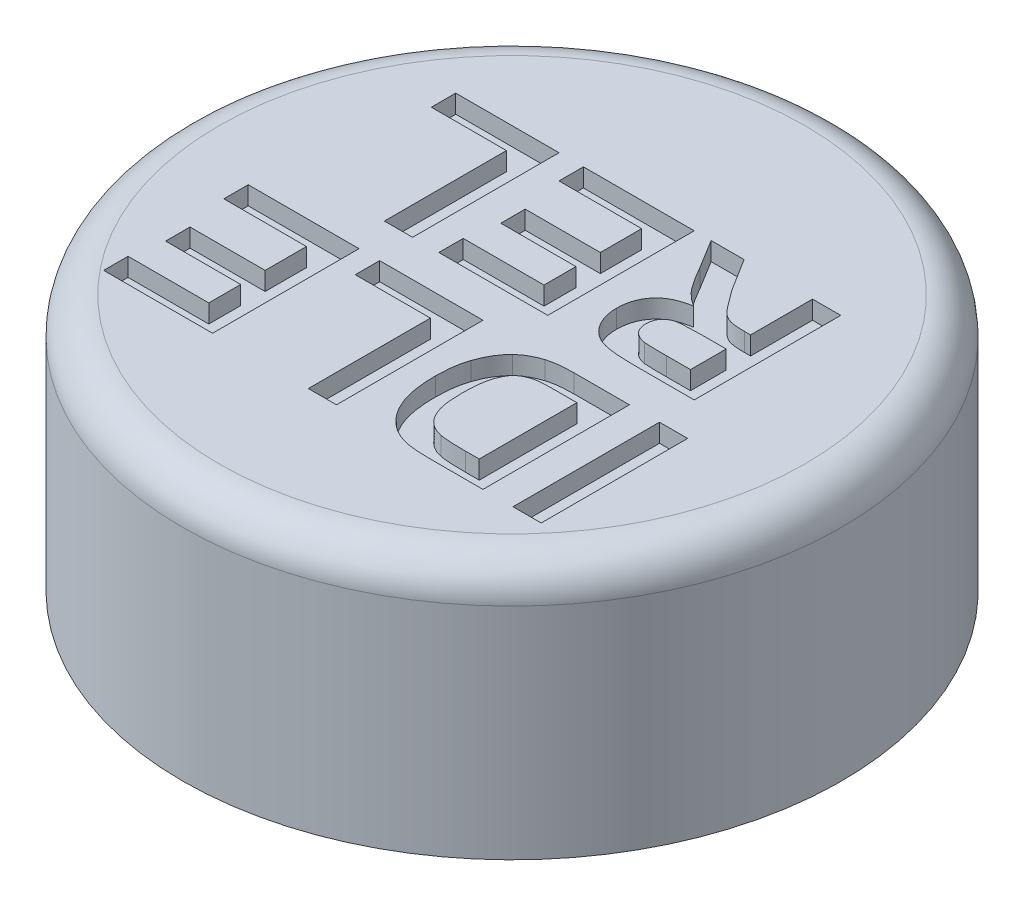
from build123d import *

# Parameters (mm, degrees)
SKETCH1_R           = 9
BOSS_EXTRUDE1_DEPTH = 7
SKETCH2_R           = 5.2
CUT_EXTRUDE1_DEPTH  = 4.5
SKETCH3_R           = 7.8
CUT_EXTRUDE2_DEPTH  = 3
SKETCH5_W           = 0.769230769
SKETCH5_H           = 4
CUT_EXTRUDE3_DEPTH  = 0.5
CUT_EXTRUDE4_DEPTH  = 0.5
FILLET1_R           = 1


with BuildPart() as part:
    # Sketch1 → Boss-Extrude1 (new body)
    with BuildSketch(Plane(origin=(0, 0, 0), x_dir=(1, 0, 0), z_dir=(0, 1, 0))):
        Circle(SKETCH1_R)
    extrude(amount=BOSS_EXTRUDE1_DEPTH)

    # Sketch2 → Cut-Extrude1 (cut)
    with BuildSketch(Plane.XZ):
        Circle(SKETCH2_R)
    extrude(amount=-CUT_EXTRUDE1_DEPTH, mode=Mode.SUBTRACT)

    # Sketch3 → Cut-Extrude2 (cut)
    with BuildSketch(Plane.XZ):
        Circle(SKETCH3_R)
    extrude(amount=-CUT_EXTRUDE2_DEPTH, mode=Mode.SUBTRACT)

    # Sketch5 → Cut-Extrude3 (cut)
    with BuildSketch(Plane(origin=(0, 7, 0), x_dir=(1, 0, 0), z_dir=(0, 1, 0))):
        with Locations((5.410256411, -3)):
            Rectangle(SKETCH5_W, SKETCH5_H)
        with BuildLine():
            Line((4.205128205, -5), (2.737980769, -5))
            add(Edge.make_bspline(
                [(2.737980769, -5), (2.697910591, -5.000020773), (2.619884646, -5.000061222), (2.506648571, -4.99536357), (2.400758284, -4.990638349), (2.302517715, -4.981179492), (2.211586037, -4.971264931), (2.127800077, -4.958712352), (2.051689115, -4.942624847), (2.003693585, -4.929937926), (1.980769231, -4.923878205)],
                knots=[0, 0, 0, 0, 0.000120195, 0.000234048, 0.000339965, 0.000438118, 0.000530057, 0.00061437, 0.000692161, 0.00076329, 0.00076329, 0.00076329, 0.00076329], degree=3))
            add(Edge.make_bspline(
                [(1.980769231, -4.923878205), (1.95205135, -4.914648987), (1.895037801, -4.896326238), (1.812261405, -4.862109411), (1.732255551, -4.824099599), (1.655496543, -4.78030702), (1.581999635, -4.731772666), (1.512013664, -4.677439933), (1.444620336, -4.619108388), (1.358904708, -4.534402974), (1.261026847, -4.416891893), (1.158022034, -4.261629883), (1.070596936, -4.091031256), (1.010066255, -3.938431484), (0.969887253, -3.808154415), (0.943491291, -3.703575528), (0.921020489, -3.593450986), (0.90389919, -3.477538623), (0.889277146, -3.356538592), (0.878759779, -3.229862465), (0.873557702, -3.097533027), (0.872390419, -3.007482273), (0.871794872, -2.961538462)],
                knots=[0, 0, 0, 0, 9.046e-05, 0.00017959, 0.00026847, 0.00035603, 0.000444481, 0.000532468, 0.000621641, 0.000711731, 0.000893734, 0.001079301, 0.001269598, 0.001467794, 0.001570948, 0.001678418, 0.001791248, 0.001907972, 0.002029822, 0.002156852, 0.002289183, 0.002427024, 0.002427024, 0.002427024, 0.002427024], degree=3))
            add(Edge.make_bspline(
                [(0.871794872, -2.961538462), (0.87337892, -2.882155908), (0.876447035, -2.728401286), (0.898619166, -2.506502016), (0.936077268, -2.301135264), (0.974814458, -2.172785814), (0.993589744, -2.110576923)],
                knots=[0, 0, 0, 0, 0.000238116, 0.000461202, 0.00066833, 0.000863145, 0.000863145, 0.000863145, 0.000863145], degree=3))
            add(Edge.make_bspline(
                [(0.993589744, -2.110576923), (1.006317082, -2.074915492), (1.031436326, -2.004532497), (1.074785292, -1.902887961), (1.121973712, -1.806504393), (1.173500658, -1.715626773), (1.228822086, -1.62970308), (1.288033978, -1.548754179), (1.351182657, -1.472951591), (1.397091862, -1.426764147), (1.419871795, -1.403846154)],
                knots=[0, 0, 0, 0, 0.000113573, 0.000224153, 0.0003313, 0.000435359, 0.000537377, 0.000637704, 0.000736092, 0.000832994, 0.000832994, 0.000832994, 0.000832994], degree=3))
            add(Edge.make_bspline(
                [(1.419871795, -1.403846154), (1.456929662, -1.370405848), (1.532776155, -1.301963434), (1.667214693, -1.217769185), (1.817768587, -1.142451393), (1.927370303, -1.104523727), (1.983974359, -1.084935897)],
                knots=[0, 0, 0, 0, 0.000149488, 0.000305958, 0.000474023, 0.000653524, 0.000653524, 0.000653524, 0.000653524], degree=3))
            add(Edge.make_bspline(
                [(1.983974359, -1.084935897), (2.006855011, -1.077914736), (2.05434262, -1.06334268), (2.129623695, -1.04766662), (2.210089518, -1.031664601), (2.296270547, -1.020078587), (2.387974587, -1.011424752), (2.485238968, -1.005058257), (2.588108042, -1.001051054), (2.658650161, -1.000355546), (2.694711538, -1)],
                knots=[0, 0, 0, 0, 7.1763e-05, 0.00014894, 0.000230502, 0.000317871, 0.000409641, 0.000506808, 0.000610251, 0.000718436, 0.000718436, 0.000718436, 0.000718436], degree=3))
            Line((2.694711538, -1), (4.205128205, -1))
            Line((4.205128205, -1), (4.205128205, -5))
        make_face()
        with BuildLine():
            Line((3.435897436, -4.333333333), (3.435897436, -1.666666667))
            Line((3.435897436, -1.666666667), (2.802884615, -1.666666667))
            add(Edge.make_bspline(
                [(2.802884615, -1.666666667), (2.774305746, -1.666893317), (2.719280505, -1.667329704), (2.639657572, -1.668611977), (2.566484766, -1.672083332), (2.499378764, -1.67567909), (2.438514268, -1.681619911), (2.383626448, -1.687462935), (2.335020835, -1.695637203), (2.305000814, -1.702089862), (2.290865385, -1.705128205)],
                knots=[0, 0, 0, 0, 8.5741e-05, 0.000165084, 0.000238872, 0.000305499, 0.000366654, 0.000422313, 0.000471053, 0.000514426, 0.000514426, 0.000514426, 0.000514426], degree=3))
            add(Edge.make_bspline(
                [(2.290865385, -1.705128205), (2.257758607, -1.713962736), (2.193275336, -1.731170071), (2.102734305, -1.769530175), (2.020806336, -1.815807442), (1.946119388, -1.871453867), (1.878810988, -1.941778078), (1.82135504, -2.03171723), (1.768181074, -2.138982356), (1.731767531, -2.241661907), (1.705629958, -2.333372881), (1.687936966, -2.410348165), (1.673954673, -2.493627638), (1.661928077, -2.582882626), (1.652210302, -2.677998353), (1.646163442, -2.779318297), (1.642036423, -2.886718431), (1.641368951, -2.960465891), (1.641025641, -2.998397436)],
                knots=[0, 0, 0, 0, 0.000102692, 0.000200018, 0.000294038, 0.000384423, 0.000478504, 0.000584289, 0.00070326, 0.000837095, 0.000910398, 0.000989316, 0.001073888, 0.001163639, 0.001259475, 0.00136064, 0.001468086, 0.001581879, 0.001581879, 0.001581879, 0.001581879], degree=3))
            add(Edge.make_bspline(
                [(1.641025641, -2.998397436), (1.641366309, -3.036329099), (1.642026246, -3.109809877), (1.646146967, -3.216409167), (1.65215975, -3.316133669), (1.66194711, -3.409106285), (1.673786, -3.495456774), (1.687936315, -3.575253977), (1.705508526, -3.647988287), (1.731729122, -3.734352219), (1.771023479, -3.831826218), (1.826640195, -3.937252659), (1.89115508, -4.029204972), (1.96492421, -4.107478292), (2.048966987, -4.172456802), (2.142944706, -4.225512064), (2.247177856, -4.267813901), (2.321557505, -4.285687757), (2.359775641, -4.294871795)],
                knots=[0, 0, 0, 0, 0.000113793, 0.000220439, 0.000320005, 0.000413449, 0.000500819, 0.000581446, 0.000656463, 0.000725154, 0.000852076, 0.00097109, 0.001082029, 0.00118802, 0.001292522, 0.001399462, 0.001510909, 0.001628695, 0.001628695, 0.001628695, 0.001628695], degree=3))
            add(Edge.make_bspline(
                [(2.359775641, -4.294871795), (2.376312881, -4.29794487), (2.412721552, -4.304710606), (2.47313859, -4.312607947), (2.544285023, -4.318515636), (2.626000772, -4.324397887), (2.718200565, -4.327911619), (2.821022591, -4.331437724), (2.934559714, -4.332665305), (3.013889136, -4.333104258), (3.055288462, -4.333333333)],
                knots=[0, 0, 0, 0, 5.0455e-05, 0.000111083, 0.000182685, 0.000264608, 0.000356842, 0.000459457, 0.00057325, 0.000697451, 0.000697451, 0.000697451, 0.000697451], degree=3))
            Line((3.055288462, -4.333333333), (3.435897436, -4.333333333))
        make_face(mode=Mode.SUBTRACT)
        Polygon((0.205128205, -1), (0.205128205, -5), (-0.564102564, -5), (-0.564102564, -1.666666667), (-2.615384615, -1.666666667), (-2.615384615, -1), align=None)
        Polygon((-3.179487179, -1), (-3.179487179, -5), (-6.153846154, -5), (-6.153846154, -4.333333333), (-3.948717949, -4.333333333), (-3.948717949, -3.461538462), (-6, -3.461538462), (-6, -2.794871795), (-3.948717949, -2.794871795), (-3.948717949, -1.666666667), (-6.205128205, -1.666666667), (-6.205128205, -1), align=None)
    extrude(amount=-CUT_EXTRUDE3_DEPTH, mode=Mode.SUBTRACT)

    # Sketch6 → Cut-Extrude4 (cut)
    with BuildSketch(Plane(origin=(0, 7, 0), x_dir=(1, 0, 0), z_dir=(0, 1, 0))):
        with BuildLine():
            Line((4.974358974, 4), (4.974358974, 0))
            Line((4.974358974, 0), (3.295673077, 0))
            add(Edge.make_bspline(
                [(3.295673077, 0), (3.244656189, 0.000314595), (3.146337308, 0.000920877), (3.004148455, 0.005337109), (2.873020444, 0.014602444), (2.752362673, 0.025059771), (2.642523762, 0.040436603), (2.543239699, 0.058491395), (2.4548307, 0.079829394), (2.376321785, 0.104951432), (2.305015138, 0.13438236), (2.238356687, 0.168699813), (2.175716471, 0.209212905), (2.116273293, 0.254220094), (2.059796402, 0.303841845), (2.007828482, 0.359377529), (1.959465651, 0.420003942), (1.91474651, 0.485215645), (1.875351769, 0.55472497), (1.839355313, 0.626299533), (1.810052841, 0.700701015), (1.785849265, 0.777578925), (1.766515076, 0.856766352), (1.753095514, 0.938464618), (1.744717827, 1.022525849), (1.74396995, 1.079306772), (1.743589744, 1.108173077)],
                knots=[0, 0, 0, 0, 0.000153053, 0.000294962, 0.000426667, 0.000547382, 0.000658208, 0.000759262, 0.000850019, 0.000930853, 0.001006297, 0.001081199, 0.001155438, 0.001229797, 0.001304725, 0.001380682, 0.001457643, 0.001537208, 0.001617612, 0.001697165, 0.001777366, 0.001857193, 0.001938817, 0.002021676, 0.002105393, 0.002191965, 0.002191965, 0.002191965, 0.002191965], degree=3))
            add(Edge.make_bspline(
                [(1.743589744, 1.108173077), (1.744286224, 1.144539297), (1.745647337, 1.215608914), (1.758452881, 1.319728342), (1.776859108, 1.419457871), (1.805312371, 1.513939812), (1.840690701, 1.603884892), (1.883914668, 1.688661153), (1.934926148, 1.769063564), (1.993987652, 1.843955337), (2.060862192, 1.913487312), (2.135927062, 1.976140216), (2.218686206, 2.032568868), (2.309816916, 2.081085477), (2.407748279, 2.123842172), (2.513770181, 2.158971332), (2.627335586, 2.187846114), (2.706353485, 2.201397652), (2.746794872, 2.208333333)],
                knots=[0, 0, 0, 0, 0.000109048, 0.00021311, 0.000314313, 0.000412936, 0.000508611, 0.000603933, 0.00069796, 0.00079382, 0.000889589, 0.000986848, 0.001086636, 0.001189531, 0.001296114, 0.001406844, 0.001524226, 0.001647282, 0.001647282, 0.001647282, 0.001647282], degree=3))
            add(Edge.make_bspline(
                [(2.746794872, 2.208333333), (2.707640736, 2.234178962), (2.631185673, 2.284646917), (2.525900993, 2.368908409), (2.430567568, 2.45585351), (2.357528523, 2.533185605), (2.303398976, 2.602405652), (2.258015887, 2.661686081), (2.210110874, 2.73079772), (2.159466003, 2.80939525), (2.103560321, 2.895922338), (2.045524258, 2.992115587), (1.983731539, 3.097039665), (1.942198351, 3.170342766), (1.920673077, 3.208333333)],
                knots=[0, 0, 0, 0, 0.000140684, 0.000274709, 0.000404016, 0.000527616, 0.000593189, 0.000667549, 0.000751573, 0.00084536, 0.000948053, 0.001060601, 0.001182359, 0.001313351, 0.001313351, 0.001313351, 0.001313351], degree=3))
            Line((1.920673077, 3.208333333), (1.435897436, 4))
            Line((1.435897436, 4), (2.334935897, 4))
            Line((2.334935897, 4), (2.903846154, 3.092147436))
            add(Edge.make_bspline(
                [(2.903846154, 3.092147436), (2.929958101, 3.055776468), (2.979811177, 2.986336814), (3.052024516, 2.887850104), (3.117216524, 2.799574088), (3.177271706, 2.722907673), (3.228446247, 2.654975961), (3.275376747, 2.599409969), (3.3142806, 2.552905061), (3.358463953, 2.506948951), (3.409427464, 2.459369033), (3.473691572, 2.415041948), (3.537635914, 2.376748662), (3.607972505, 2.349220324), (3.689078292, 2.329889363), (3.786537194, 2.317384), (3.903142214, 2.308265916), (3.987423986, 2.307893203), (4.032852564, 2.307692308)],
                knots=[0, 0, 0, 0, 0.000134319, 0.000256443, 0.00036638, 0.000463503, 0.000548609, 0.000621451, 0.000681681, 0.000730421, 0.000812672, 0.000890264, 0.000964208, 0.001035779, 0.001115847, 0.001213754, 0.001330274, 0.001466513, 0.001466513, 0.001466513, 0.001466513], degree=3))
            Line((4.032852564, 2.307692308), (4.205128205, 2.307692308))
            Line((4.205128205, 2.307692308), (4.205128205, 4))
            Line((4.205128205, 4), (4.974358974, 4))
        make_face()
        with BuildLine():
            Line((4.205128205, 1.641025641), (3.585737179, 1.641025641))
            add(Edge.make_bspline(
                [(3.585737179, 1.641025641), (3.537924983, 1.640924171), (3.446834668, 1.640730853), (3.317303349, 1.637890583), (3.201851829, 1.635536722), (3.100652023, 1.62939682), (3.013492644, 1.623540539), (2.940484111, 1.615723821), (2.881530198, 1.606548433), (2.822649418, 1.592272416), (2.762314743, 1.567418631), (2.69809608, 1.531947891), (2.642753555, 1.48605635), (2.596115747, 1.432231557), (2.558660274, 1.370578761), (2.532099038, 1.301139914), (2.515975681, 1.224558376), (2.513893561, 1.171020793), (2.512820513, 1.143429487)],
                knots=[0, 0, 0, 0, 0.000143432, 0.000273262, 0.000388691, 0.000489808, 0.000577383, 0.000650738, 0.000710017, 0.00075627, 0.000832155, 0.000905006, 0.000975591, 0.001046599, 0.001117782, 0.001190844, 0.001268634, 0.001351357, 0.001351357, 0.001351357, 0.001351357], degree=3))
            add(Edge.make_bspline(
                [(2.512820513, 1.143429487), (2.514147893, 1.112583365), (2.516708858, 1.053070746), (2.537944647, 0.968521102), (2.572547702, 0.892881875), (2.62247865, 0.827926358), (2.685395757, 0.773578281), (2.759962651, 0.730382478), (2.845793567, 0.697708873), (2.907602442, 0.685741398), (2.939903846, 0.679487179)],
                knots=[0, 0, 0, 0, 9.2429e-05, 0.000178327, 0.0002597, 0.000340311, 0.000422097, 0.000507575, 0.000597608, 0.000696166, 0.000696166, 0.000696166, 0.000696166], degree=3))
            add(Edge.make_bspline(
                [(2.939903846, 0.679487179), (2.950579428, 0.678314162), (2.975882797, 0.675533866), (3.020565547, 0.673748204), (3.077698175, 0.671003446), (3.147972216, 0.669881725), (3.230759843, 0.667915447), (3.326390259, 0.667554388), (3.434559638, 0.666400832), (3.510950392, 0.666574812), (3.551282051, 0.666666667)],
                knots=[0, 0, 0, 0, 3.2211e-05, 7.6347e-05, 0.00013409, 0.000203819, 0.000287168, 0.000382524, 0.0004907, 0.000611694, 0.000611694, 0.000611694, 0.000611694], degree=3))
            Line((3.551282051, 0.666666667), (4.205128205, 0.666666667))
            Line((4.205128205, 0.666666667), (4.205128205, 1.641025641))
        make_face(mode=Mode.SUBTRACT)
        Polygon((0.974358974, 4), (0.974358974, 0), (-2, 0), (-2, 0.666666667), (0.205128205, 0.666666667), (0.205128205, 1.538461538), (-1.846153846, 1.538461538), (-1.846153846, 2.205128205), (0.205128205, 2.205128205), (0.205128205, 3.333333333), (-2.051282051, 3.333333333), (-2.051282051, 4), align=None)
        Polygon((-2.717948718, 4), (-2.717948718, 0), (-3.487179487, 0), (-3.487179487, 3.333333333), (-5.538461538, 3.333333333), (-5.538461538, 4), align=None)
    extrude(amount=-CUT_EXTRUDE4_DEPTH, mode=Mode.SUBTRACT)

    # Fillet1
    fillet1_edges = [part.edges().sort_by_distance(p)[0] for p in [
        (-9, 7, 0),
    ]]
    fillet(fillet1_edges, radius=FILLET1_R)


solid = part.part
